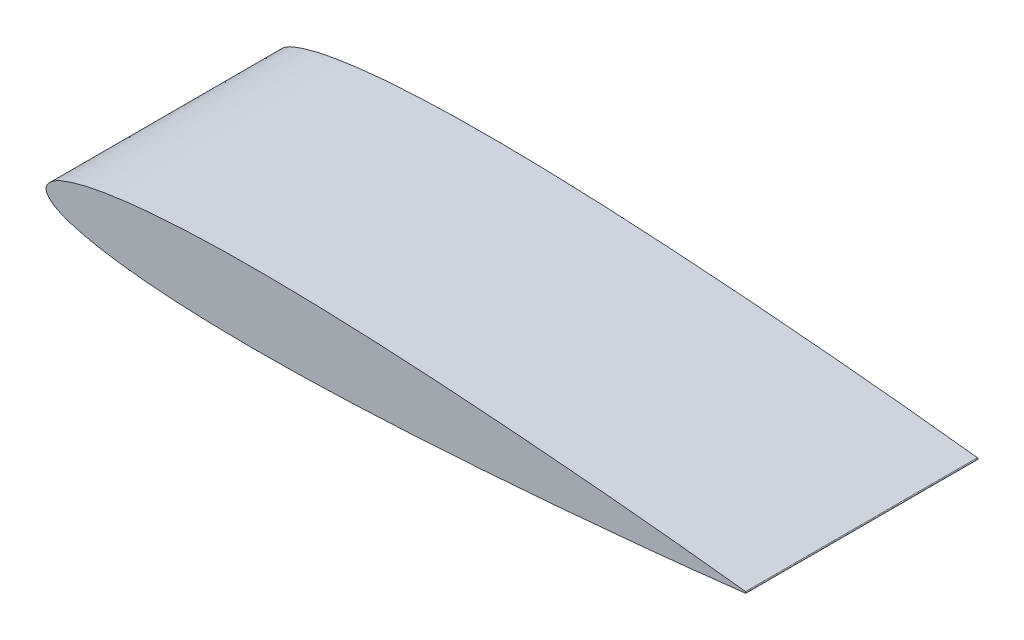
from build123d import *

# Parameters (mm, degrees)
BOSS_EXTRUDE1_DEPTH = 24


with BuildPart() as part:
    # Sketch1 → Boss-Extrude1 (new body)
    with BuildSketch(Plane.XY):
        with BuildLine():
            ThreePointArc((72.4, 0.07602), (72.467794719, 0), (72.4, -0.07602))
            add(Edge.make_bspline(
                [(72.4, 0.07602), (71.19351403, 0.214479461), (68.781382489, 0.491301937), (63.955829083, 1.005686548), (57.923781887, 1.596888097), (50.683324552, 2.223428481), (43.443470108, 2.769964023), (36.203441774, 3.215533146), (28.962939961, 3.532564842), (22.926980285, 3.643458715), (18.099079373, 3.599593107), (14.477336842, 3.480467862), (10.853015469, 3.250586776), (7.835065311, 2.93038711), (5.419974159, 2.546513461), (3.604801256, 2.171667489), (2.061477724, 1.695409553), (0.781540186, 1.156613975), (-0.462789704, 0), (0.781540186, -1.156613975), (2.061477724, -1.695409553), (3.604801256, -2.171667489), (5.419974159, -2.546513461), (7.835065311, -2.93038711), (10.853015469, -3.250586776), (14.477336842, -3.480467862), (18.099079373, -3.599593107), (22.926980285, -3.643458715), (28.962939961, -3.532564842), (36.203441774, -3.215533146), (43.443470108, -2.769964023), (50.683324552, -2.223428481), (57.923781887, -1.596888097), (63.955829083, -1.005686548), (68.781382489, -0.491301937), (71.19351403, -0.214479461), (72.4, -0.07602)],
                knots=[0, 0, 0, 0, 0.024823556, 0.049629821, 0.09919708, 0.148712653, 0.19818214, 0.247604473, 0.296979943, 0.346317596, 0.370984298, 0.39566402, 0.420382182, 0.445198051, 0.457689209, 0.470304283, 0.48322923, 0.490069174, 0.5, 0.509930826, 0.51677077, 0.529695717, 0.542310791, 0.554801949, 0.579617818, 0.60433598, 0.629015702, 0.653682404, 0.703020057, 0.752395527, 0.80181786, 0.851287347, 0.90080292, 0.950370179, 0.975176444, 1, 1, 1, 1], degree=3))
        make_face()
    extrude(amount=BOSS_EXTRUDE1_DEPTH)


solid = part.part
